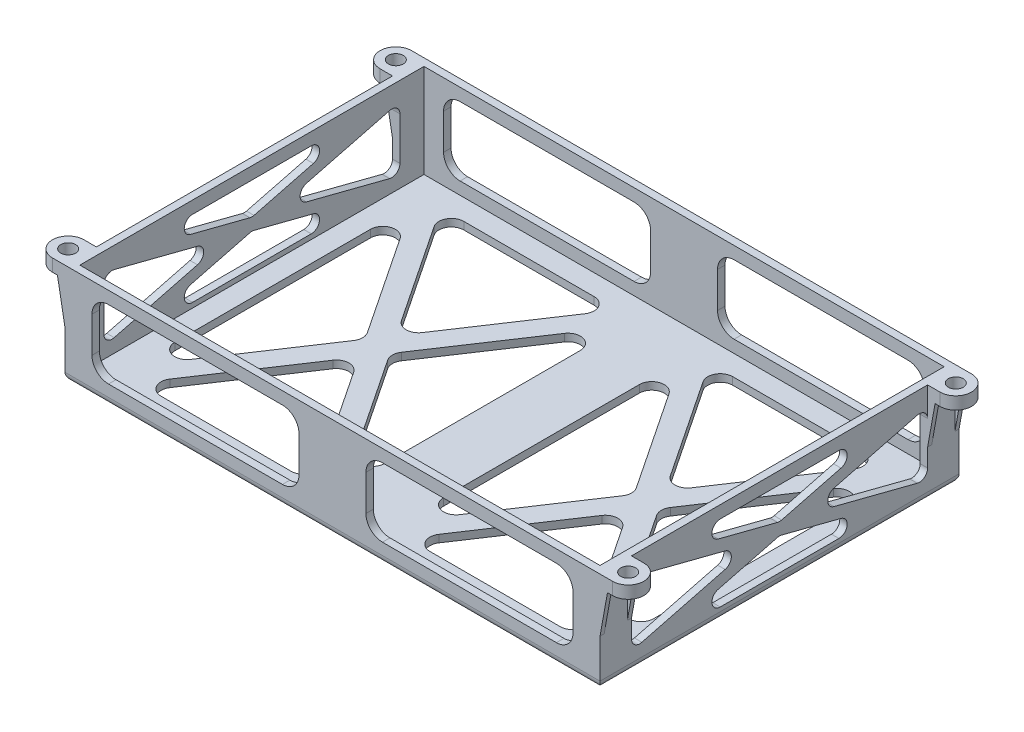
from build123d import *

# Parameters (mm, degrees)
SKETCH1_W               = 164.084
SKETCH1_H               = 110.109
BOSS_EXTRUDE1_DEPTH     = 30.988
SHELL1_T                = -2.286
SKETCH7_R               = 2.286
BOSS_EXTRUDE7_DEPTH     = 3.81
CUT_EXTRUDE1_DEPTH      = 161.798
FILLET1_R               = 2.54
FILLET1_OF_MIRROR1_R    = 2.54
CUT_EXTRUDE2_DEPTH      = 206.956922372
CUT_EXTRUDE2_DEPTH_BACK = 206.956922372
FILLET2_R               = 2.54
CUT_EXTRUDE3_DEPTH      = 207.833254302
RIB1_REACH              = 204.198
SKETCH40_WALL_W         = 419.300259164
SKETCH40_WALL_H         = 1.27
RIB2_REACH              = 209.163
SKETCH39_WALL_W         = 429.229799992
SKETCH39_WALL_H         = 1.27
MIRROR3_COPY_1_REACH    = 204.198
MIRROR3_COPY_1_SKETCH_W = 419.300259164
MIRROR3_COPY_1_SKETCH_H = 1.27
MIRROR3_COPY_2_REACH    = 209.163
MIRROR3_COPY_2_SKETCH_W = 429.229799992
MIRROR3_COPY_2_SKETCH_H = 1.27


with BuildPart() as part:
    # Sketch1 → Boss-Extrude1 (new body)
    with BuildSketch(Plane(origin=(0, 0, 0), x_dir=(1, 0, 0), z_dir=(0, 1, 0))):
        with Locations((-82.042, -55.0545)):
            Rectangle(SKETCH1_W, SKETCH1_H)
    extrude(amount=BOSS_EXTRUDE1_DEPTH)

    # Shell1
    shell1_openings = [part.faces().sort_by_distance(p)[0] for p in [
        (-82.042, 30.988, 55.0545),
    ]]
    offset(amount=SHELL1_T, openings=shell1_openings, kind=Kind.INTERSECTION)

    # Sketch7 → Boss-Extrude7 (add)
    with BuildSketch(Plane(origin=(0, 30.988, 0), x_dir=(1, 0, 0), z_dir=(0, 1, 0))):
        with BuildLine():
            Line((-167.894, 0), (-164.084, 0))
            Line((-164.084, 0), (-164.084, -9.652))
            Line((-164.084, -9.652), (-167.894, -9.652))
            ThreePointArc((-167.894, -9.652), (-172.72, -4.826), (-167.894, 0))
        make_face()
        with Locations(Location((-167.894, -4.826, 0), (0, 0, 270))):
            Circle(SKETCH7_R, mode=Mode.SUBTRACT)
        with BuildLine():
            Line((-164.084, -100.457), (-167.894, -100.457))
            ThreePointArc((-167.894, -100.457), (-172.72, -105.283), (-167.894, -110.109))
            Line((-167.894, -110.109), (-164.084, -110.109))
            Line((-164.084, -110.109), (-164.084, -100.457))
        make_face()
        with Locations(Location((-167.894, -105.283, 0), (0, 0, 270))):
            Circle(SKETCH7_R, mode=Mode.SUBTRACT)
        with BuildLine():
            Line((3.81, -110.109), (0, -110.109))
            Line((0, -110.109), (0, -100.457))
            Line((0, -100.457), (3.81, -100.457))
            ThreePointArc((3.81, -100.457), (8.636, -105.283), (3.81, -110.109))
        make_face()
        with Locations(Location((3.81, -105.283, 0), (0, 0, 270))):
            Circle(SKETCH7_R, mode=Mode.SUBTRACT)
        with BuildLine():
            Line((0, -9.652), (3.81, -9.652))
            ThreePointArc((3.81, -9.652), (8.636, -4.826), (3.81, 0))
            Line((3.81, 0), (0, 0))
            Line((0, 0), (0, -9.652))
        make_face()
        with Locations(Location((3.81, -4.826, 0), (0, 0, 270))):
            Circle(SKETCH7_R, mode=Mode.SUBTRACT)
    extrude(amount=-BOSS_EXTRUDE7_DEPTH)

    # Sketch33 → Cut-Extrude1 (cut)
    with BuildSketch(Plane(origin=(0, 0, 0), x_dir=(0, 0, -1), z_dir=(1, 0, 0))):
        Polygon((-93.322813545, 3.81), (-16.786186455, 3.81), (-55.0545, 13.6580695), align=None)
        Polygon((-9.652, 5.6459305), (-9.652, 25.3420695), (-47.920313545, 15.494), align=None)
        Polygon((-62.188686455, 15.494), (-100.457, 25.3420695), (-100.457, 5.6459305), align=None)
        Polygon((-55.0545, 17.3299305), (-16.786186455, 27.178), (-93.322813545, 27.178), align=None)
    cut_extrude1 = extrude(amount=-CUT_EXTRUDE1_DEPTH, mode=Mode.SUBTRACT)

    # Fillet1
    fillet1_edges = [part.edges().sort_by_distance(p)[0] for p in [
        (-1.143, 27.178, 16.786186455),
        (-1.143, 17.3299305, 55.0545),
        (-1.143, 27.178, 93.322813545),
        (-1.143, 3.81, 16.786186455),
        (-1.143, 3.81, 93.322813545),
        (-1.143, 13.6580695, 55.0545),
        (-1.143, 25.3420695, 9.652),
        (-1.143, 5.6459305, 9.652),
        (-1.143, 15.494, 47.920313545),
        (-1.143, 15.494, 62.188686455),
        (-1.143, 5.6459305, 100.457),
        (-1.143, 25.3420695, 100.457),
    ]]
    fillet(fillet1_edges, radius=FILLET1_R)

    # Mirror1: Cut-Extrude1 across plane
    add(cut_extrude1.mirror(Plane.ZY.offset(82.042)), mode=Mode.SUBTRACT)

    # Fillet1 of Mirror1
    fillet1_of_mirror1_edges = [part.edges().sort_by_distance(p)[0] for p in [
        (-162.941, 27.178, 16.786186455),
        (-162.941, 17.3299305, 55.0545),
        (-162.941, 27.178, 93.322813545),
        (-162.941, 3.81, 16.786186455),
        (-162.941, 3.81, 93.322813545),
        (-162.941, 13.6580695, 55.0545),
        (-162.941, 25.3420695, 9.652),
        (-162.941, 5.6459305, 9.652),
        (-162.941, 15.494, 47.920313545),
        (-162.941, 15.494, 62.188686455),
        (-162.941, 5.6459305, 100.457),
        (-162.941, 25.3420695, 100.457),
    ]]
    fillet(fillet1_of_mirror1_edges, radius=FILLET1_OF_MIRROR1_R)

    # Sketch34 → Cut-Extrude2 (cut, two sides)
    with BuildSketch(Plane(origin=(0, 0, 107.823), x_dir=(-1, 0, 0), z_dir=(0, 0, -1))) as cut_extrude2_sk:
        with BuildLine():
            Line((150.718, 6.096), (97.378, 6.096))
            ThreePointArc((97.378, 6.096), (93.785897552, 7.583897552), (92.298, 11.176))
            Line((92.298, 11.176), (92.298, 22.098))
            ThreePointArc((92.298, 22.098), (93.785897552, 25.690102448), (97.378, 27.178))
            Line((97.378, 27.178), (150.718, 27.178))
            ThreePointArc((150.718, 27.178), (154.310102448, 25.690102448), (155.798, 22.098))
            Line((155.798, 22.098), (155.798, 11.176))
            ThreePointArc((155.798, 11.176), (154.310102448, 7.583897552), (150.718, 6.096))
        make_face()
        with BuildLine():
            Line((66.706, 6.096), (13.366, 6.096))
            ThreePointArc((13.366, 6.096), (9.773897552, 7.583897552), (8.286, 11.176))
            Line((8.286, 11.176), (8.286, 22.098))
            ThreePointArc((8.286, 22.098), (9.773897552, 25.690102448), (13.366, 27.178))
            Line((13.366, 27.178), (66.706, 27.178))
            ThreePointArc((66.706, 27.178), (70.298102448, 25.690102448), (71.786, 22.098))
            Line((71.786, 22.098), (71.786, 11.176))
            ThreePointArc((71.786, 11.176), (70.298102448, 7.583897552), (66.706, 6.096))
        make_face()
    extrude(amount=CUT_EXTRUDE2_DEPTH, mode=Mode.SUBTRACT)
    extrude(cut_extrude2_sk.sketch, amount=-CUT_EXTRUDE2_DEPTH_BACK, mode=Mode.SUBTRACT)

    # Fillet2
    fillet2_edges = [part.edges().sort_by_distance(p)[0] for p in [
        (-82.042, 0, 0),
        (-164.084, 0, 55.0545),
        (-82.042, 0, 110.109),
        (0, 0, 55.0545),
    ]]
    fillet(fillet2_edges, radius=FILLET2_R)

    # Sketch36 → Cut-Extrude3 (cut, through all)
    with BuildSketch(Plane(origin=(0, 2.286, 0), x_dir=(1, 0, 0), z_dir=(0, 1, 0))):
        with BuildLine():
            Line((-103.293501595, -8.636), (-143.246498405, -8.636))
            ThreePointArc((-143.246498405, -8.636), (-146.605128114, -10.647193039), (-146.417903392, -14.557466413))
            Line((-146.417903392, -14.557466413), (-126.441404986, -44.562000829))
            ThreePointArc((-126.441404986, -44.562000829), (-123.27, -46.260534416), (-120.098595014, -44.562000829))
            Line((-120.098595014, -44.562000829), (-100.122096608, -14.557466413))
            ThreePointArc((-100.122096608, -14.557466413), (-99.934871886, -10.647193039), (-103.293501595, -8.636))
        make_face()
        with BuildLine():
            Line((-91.092, -85.059034416), (-91.092, -25.049965584))
            ThreePointArc((-91.092, -25.049965584), (-93.799038758, -21.403107142), (-98.073404986, -22.938499171))
            Line((-98.073404986, -22.938499171), (-118.049903392, -52.943033587))
            ThreePointArc((-118.049903392, -52.943033587), (-118.688498405, -55.0545), (-118.049903392, -57.165966413))
            Line((-118.049903392, -57.165966413), (-98.073404986, -87.170500829))
            ThreePointArc((-98.073404986, -87.170500829), (-93.799038758, -88.705892858), (-91.092, -85.059034416))
        make_face()
        with BuildLine():
            Line((-155.448, -25.049965584), (-155.448, -85.059034416))
            ThreePointArc((-155.448, -85.059034416), (-152.740961242, -88.705892858), (-148.466595014, -87.170500829))
            Line((-148.466595014, -87.170500829), (-128.490096608, -57.165966413))
            ThreePointArc((-128.490096608, -57.165966413), (-127.851501595, -55.0545), (-128.490096608, -52.943033587))
            Line((-128.490096608, -52.943033587), (-148.466595014, -22.938499171))
            ThreePointArc((-148.466595014, -22.938499171), (-152.740961242, -21.403107142), (-155.448, -25.049965584))
        make_face()
        with BuildLine():
            Line((-143.246498405, -101.473), (-103.293501595, -101.473))
            ThreePointArc((-103.293501595, -101.473), (-99.934871886, -99.461806961), (-100.122096608, -95.551533587))
            Line((-100.122096608, -95.551533587), (-120.098595014, -65.546999171))
            ThreePointArc((-120.098595014, -65.546999171), (-123.27, -63.848465584), (-126.441404986, -65.546999171))
            Line((-126.441404986, -65.546999171), (-146.417903392, -95.551533587))
            ThreePointArc((-146.417903392, -95.551533587), (-146.605128114, -99.461806961), (-143.246498405, -101.473))
        make_face()
        with BuildLine():
            Line((-43.985404986, -44.562000829), (-63.961903392, -14.557466413))
            ThreePointArc((-63.961903392, -14.557466413), (-64.149128114, -10.647193039), (-60.790498405, -8.636))
            Line((-60.790498405, -8.636), (-20.837501595, -8.636))
            ThreePointArc((-20.837501595, -8.636), (-17.478871886, -10.647193039), (-17.666096608, -14.557466413))
            Line((-17.666096608, -14.557466413), (-37.642595014, -44.562000829))
            ThreePointArc((-37.642595014, -44.562000829), (-40.814, -46.260534416), (-43.985404986, -44.562000829))
        make_face()
        with BuildLine():
            Line((-43.985404986, -65.546999171), (-63.961903392, -95.551533587))
            ThreePointArc((-63.961903392, -95.551533587), (-64.149128114, -99.461806961), (-60.790498405, -101.473))
            Line((-60.790498405, -101.473), (-20.837501595, -101.473))
            ThreePointArc((-20.837501595, -101.473), (-17.478871886, -99.461806961), (-17.666096608, -95.551533587))
            Line((-17.666096608, -95.551533587), (-37.642595014, -65.546999171))
            ThreePointArc((-37.642595014, -65.546999171), (-40.814, -63.848465584), (-43.985404986, -65.546999171))
        make_face()
        with BuildLine():
            Line((-46.034096608, -57.165966413), (-66.010595014, -87.170500829))
            ThreePointArc((-66.010595014, -87.170500829), (-70.284961242, -88.705892858), (-72.992, -85.059034416))
            Line((-72.992, -85.059034416), (-72.992, -25.049965584))
            ThreePointArc((-72.992, -25.049965584), (-70.284961242, -21.403107142), (-66.010595014, -22.938499171))
            Line((-66.010595014, -22.938499171), (-46.034096608, -52.943033587))
            ThreePointArc((-46.034096608, -52.943033587), (-45.395501595, -55.0545), (-46.034096608, -57.165966413))
        make_face()
        with BuildLine():
            Line((-15.617404986, -87.170500829), (-35.593903392, -57.165966413))
            ThreePointArc((-35.593903392, -57.165966413), (-36.232498405, -55.0545), (-35.593903392, -52.943033587))
            Line((-35.593903392, -52.943033587), (-15.617404986, -22.938499171))
            ThreePointArc((-15.617404986, -22.938499171), (-11.343038758, -21.403107142), (-8.636, -25.049965584))
            Line((-8.636, -25.049965584), (-8.636, -85.059034416))
            ThreePointArc((-8.636, -85.059034416), (-11.343038758, -88.705892858), (-15.617404986, -87.170500829))
        make_face()
    extrude(amount=-CUT_EXTRUDE3_DEPTH, mode=Mode.SUBTRACT)

    # Sketch40 wall → Rib1 (add, up to next)
    with BuildSketch(Plane(origin=(-165.227, 20.828, 9.652), x_dir=(0.177152998315, -0.984183323974, 0), z_dir=(0.984183323974, 0.177152998315, 0)), mode=Mode.PRIVATE) as rib1_sk1:
        with Locations((0, 0.635)):
            Rectangle(SKETCH40_WALL_W, SKETCH40_WALL_H)
    rib1_tool1 = extrude(rib1_sk1.sketch, amount=RIB1_REACH, mode=Mode.PRIVATE) - part.part
    rib1 = rib1_tool1.solids().sort_by_distance((-165.227, 20.828, 9.652))[0]
    add(rib1)

    # Sketch39 wall → Rib2 (add, up to next)
    with BuildSketch(Plane(origin=(-165.227, 20.828, 0), x_dir=(0.177152998315, -0.984183323974, 0), z_dir=(-0.984183323974, -0.177152998315, 0)), mode=Mode.PRIVATE) as rib2_sk1:
        with Locations((0, 0.635)):
            Rectangle(SKETCH39_WALL_W, SKETCH39_WALL_H)
    rib2_tool1 = extrude(rib2_sk1.sketch, amount=-RIB2_REACH, mode=Mode.PRIVATE) - part.part
    rib2 = rib2_tool1.solids().sort_by_distance((-165.227, 20.828, 0))[0]
    add(rib2)

    # Mirror2: Rib1, Rib2 across plane
    add(rib1.mirror(Plane(origin=(0, 0, 55.0545), x_dir=(1, 0, 0), z_dir=(0, 0, -1))))
    add(rib2.mirror(Plane(origin=(0, 0, 55.0545), x_dir=(1, 0, 0), z_dir=(0, 0, -1))))

    # Mirror3: Rib1, Rib2 across plane
    add(rib1.mirror(Plane.ZY.offset(82.042)))
    add(rib2.mirror(Plane.ZY.offset(82.042)))

    # Mirror3 copy 1 sketch → Mirror3 copy 1 (add, up to next)
    with BuildSketch(Plane(origin=(1.143, 20.828, 100.457), x_dir=(-0.177152998315, -0.984183323974, 0), z_dir=(-0.984183323974, 0.177152998315, 0)), mode=Mode.PRIVATE) as mirror3_copy_1_sk1:
        with Locations((0, 0.635)):
            Rectangle(MIRROR3_COPY_1_SKETCH_W, MIRROR3_COPY_1_SKETCH_H)
    mirror3_copy_1_tool1 = extrude(mirror3_copy_1_sk1.sketch, amount=MIRROR3_COPY_1_REACH, mode=Mode.PRIVATE) - part.part
    add(mirror3_copy_1_tool1.solids().sort_by_distance((1.143, 20.828, 100.457))[0])

    # Mirror3 copy 2 sketch → Mirror3 copy 2 (add, up to next)
    with BuildSketch(Plane(origin=(1.143, 20.828, 110.109), x_dir=(-0.177152998315, -0.984183323974, 0), z_dir=(0.984183323974, -0.177152998315, 0)), mode=Mode.PRIVATE) as mirror3_copy_2_sk1:
        with Locations((0, 0.635)):
            Rectangle(MIRROR3_COPY_2_SKETCH_W, MIRROR3_COPY_2_SKETCH_H)
    mirror3_copy_2_tool1 = extrude(mirror3_copy_2_sk1.sketch, amount=-MIRROR3_COPY_2_REACH, mode=Mode.PRIVATE) - part.part
    add(mirror3_copy_2_tool1.solids().sort_by_distance((1.143, 20.828, 110.109))[0])


solid = part.part
